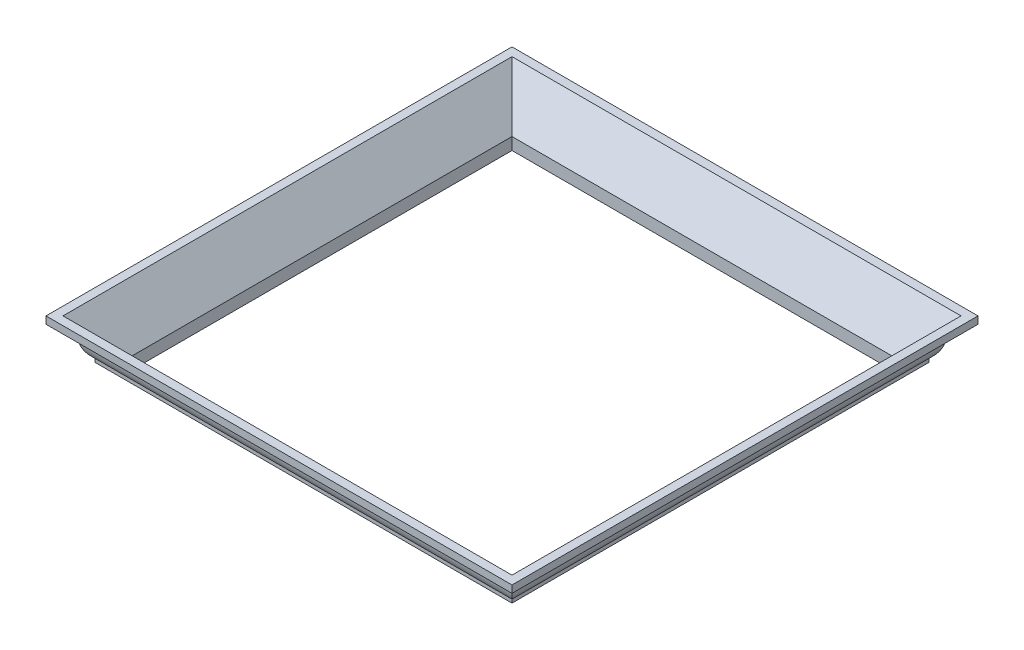
from build123d import *

# Parameters (mm, degrees)
BOSS_EXTRUDE1_DEPTH = 1219.2
CUT_EXTRUDE1_DEPTH  = 134.35


with BuildPart() as part:
    # Sketch2 → Boss-Extrude1 (new body)
    with BuildSketch(Plane.XY):
        with BuildLine():
            Line((0, 0), (0, 31.75))
            Line((0, 31.75), (79.378619653, 133.35))
            Line((79.378619653, 133.35), (101.6, 133.35))
            Line((101.6, 133.35), (101.6, 114.3))
            ThreePointArc((101.6, 114.3), (74.403120681, 104.480352771), (58.99918365, 80.009667445))
            ThreePointArc((58.99918365, 80.009667445), (52.895666714, 56.49803793), (37.615267176, 37.615267176))
            Line((37.615267176, 37.615267176), (37.615267176, 28.090267176))
            ThreePointArc((37.615267176, 28.090267176), (17.75244877, 19.862818405), (9.525, 0))
            Line((9.525, 0), (0, 0))
        make_face()
    extrude(amount=BOSS_EXTRUDE1_DEPTH)

    # Sketch3 → Cut-Extrude1 (cut, through all)
    with BuildSketch(Plane(origin=(0, 133.35, 0), x_dir=(1, 0, 0), z_dir=(0, 1, 0))):
        Polygon((101.6, 0), (0, 0), (0, -101.6), align=None)
        Polygon((101.6, -1219.2), (0, -1219.2), (0, -1117.6), align=None)
    extrude(amount=-CUT_EXTRUDE1_DEPTH, mode=Mode.SUBTRACT)

    # Mirror4: part across plane


with BuildPart() as part_1:
    add(part.part)
    add(part.part.mirror(Plane(origin=(0, 0, 1117.6), x_dir=(0.707106781, 0, 0.707106781), z_dir=(0.707106781, 0, -0.707106781))))

    # Mirror5: part across plane


with BuildPart() as part_2:
    add(part_1.part)
    add(part_1.part.mirror(Plane(origin=(-1016, 0, 1117.6), x_dir=(-0.707106781, 0, 0.707106781), z_dir=(0.707106781, 0, 0.707106781))))


solid = part_2.part
